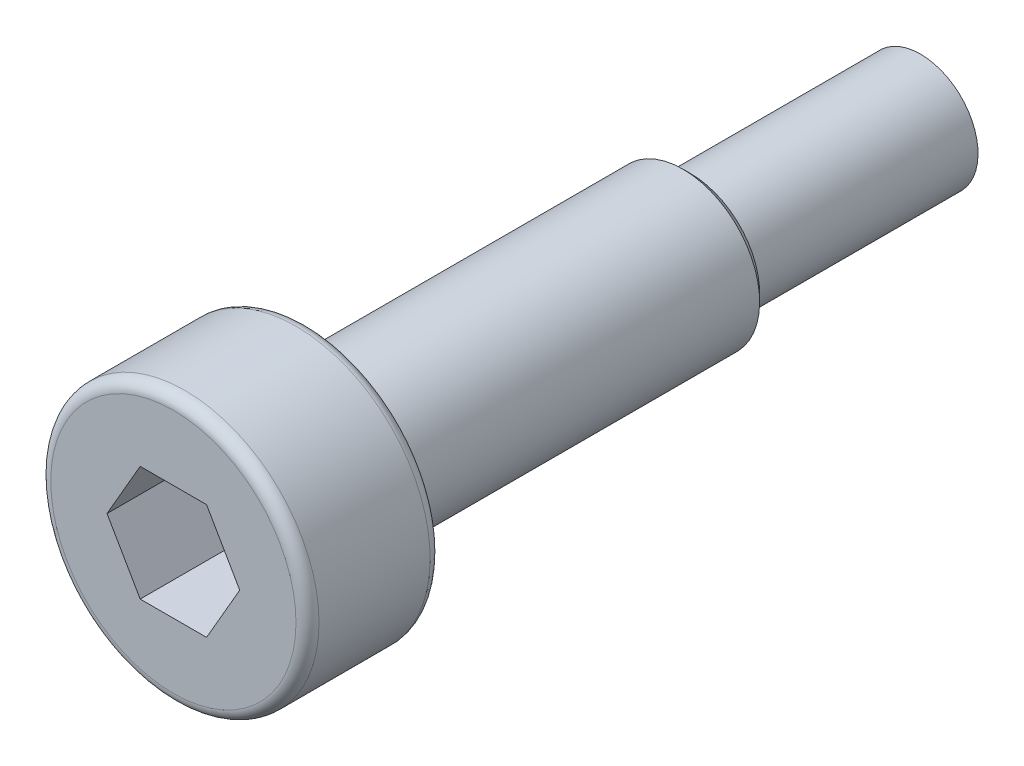
from build123d import *

# Parameters (mm, degrees)
FILLET_1_R          = 0.3
CUT_EXTRUDE_1_DEPTH = 2.4
CHAMFER_1_SIZE      = 0.2


with BuildPart() as part:
    # 草图1 → 旋转1 (revolve)
    with BuildSketch(Plane(origin=(0, 0, 0), x_dir=(0, 0, -1), z_dir=(1, 0, 0))):
        Polygon((0, 0), (0, 1.5), (-6, 1.5), (-6, 2), (-16, 2), (-16, 3.5), (-19.5, 3.5), (-19.5, 0), align=None)
    revolve(axis=Axis((0, 0, 0), (0, 0, 1)))

    # 圆角1
    fillet_1_edges = [part.edges().sort_by_distance(p)[0] for p in [
        (0, -3.5, 19.5),
        (0, -3.5, 16),
    ]]
    fillet(fillet_1_edges, radius=FILLET_1_R)

    # 草图2 → 切除-拉伸1 (cut)
    with BuildSketch(Plane.XY.offset(19.5)):
        Polygon((1.732050808, 0), (0.866025404, 1.5), (-0.866025404, 1.5), (-1.732050808, 0), (-0.866025404, -1.5), (0.866025404, -1.5), align=None)
    extrude(amount=-CUT_EXTRUDE_1_DEPTH, mode=Mode.SUBTRACT)

    # 倒角1
    chamfer_1_edges = [part.edges().sort_by_distance(p)[0] for p in [
        (0, -2, 6),
    ]]
    chamfer(chamfer_1_edges, length=CHAMFER_1_SIZE)


solid = part.part
